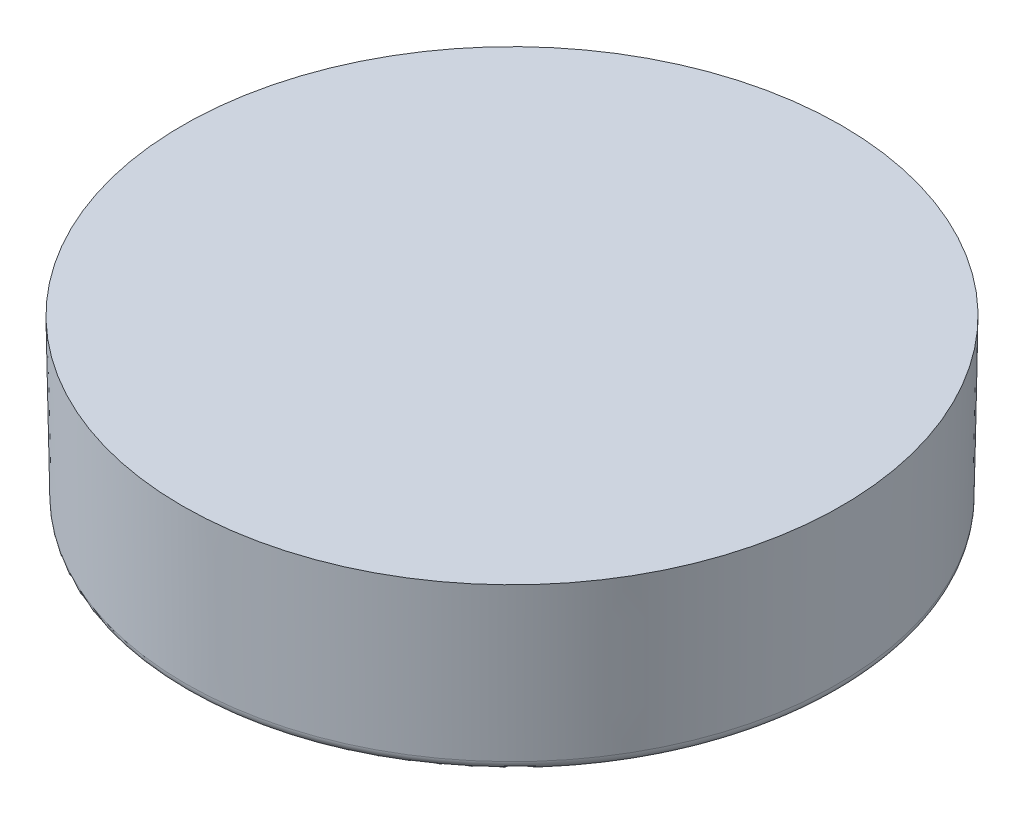
from build123d import *

# Parameters (mm, degrees)
SKETCH1_R           = 12.7
BOSS_EXTRUDE1_DEPTH = 2.3114
BOSS_EXTRUDE1_DRAFT = -1
SKETCH7_R           = 12.7
SKETCH7_R_2         = 10.922
BOSS_EXTRUDE3_DEPTH = 6.35
BOSS_EXTRUDE3_DRAFT = -1
DRAFT1_ANGLE        = 10
FILLET2_R           = 0.381


with BuildPart() as part:
    # Sketch1 → Boss-Extrude1 (with draft: the straight prism first)
    with BuildSketch(Plane(origin=(0, 0, 0), x_dir=(1, 0, 0), z_dir=(0, 1, 0))):
        Circle(SKETCH1_R)
    extrude(amount=-BOSS_EXTRUDE1_DEPTH)
    # Boss-Extrude1: the draft: its side faces are tilted about the plane it starts from
    boss_extrude1_sides = [part.faces().sort_by_distance(p)[0] for p in [
        (-12.7, -1.1557, 0),
    ]]
    draft(boss_extrude1_sides, Plane(origin=(0, 0, 0), x_dir=(1, 0, 0), z_dir=(0, 1, 0)), BOSS_EXTRUDE1_DRAFT)


with BuildPart() as boss_extrude3_tool:
    # Sketch7 → Boss-Extrude3 (with draft: the straight prism first)
    with BuildSketch(Plane(origin=(0, 0, 0), x_dir=(1, 0, 0), z_dir=(0, 1, 0))):
        Circle(SKETCH7_R)
        Circle(SKETCH7_R_2, mode=Mode.SUBTRACT)
    extrude(amount=-BOSS_EXTRUDE3_DEPTH)
    # Boss-Extrude3: the draft: its side faces are tilted about the plane it starts from
    boss_extrude3_sides = [boss_extrude3_tool.faces().sort_by_distance(p)[0] for p in [
        (-12.7, -3.175, 0),
        (-10.922, -3.175, 0),
    ]]
    draft(boss_extrude3_sides, Plane(origin=(0, 0, 0), x_dir=(1, 0, 0), z_dir=(0, 1, 0)), BOSS_EXTRUDE3_DRAFT)


with BuildPart() as part_1:
    add(part.part)

    # Boss-Extrude3: add boss_extrude3_tool
    add(boss_extrude3_tool.part)

    # Draft1
    draft1_faces = [part_1.faces().sort_by_distance(p)[0] for p in [
        (-10.99759265, -4.3307, 0),
    ]]
    draft(draft1_faces, Plane(origin=(0, -2.3114, 0), x_dir=(0, 0, -1), z_dir=(0, -1, 0)), DRAFT1_ANGLE)

    # Fillet2
    fillet2_edges = [part_1.edges().sort_by_distance(p)[0] for p in [
        (-12.589160338, -6.35, 0),
        (-11.674459781, -6.35, 0),
    ]]
    fillet(fillet2_edges, radius=FILLET2_R)


solid = part_1.part
